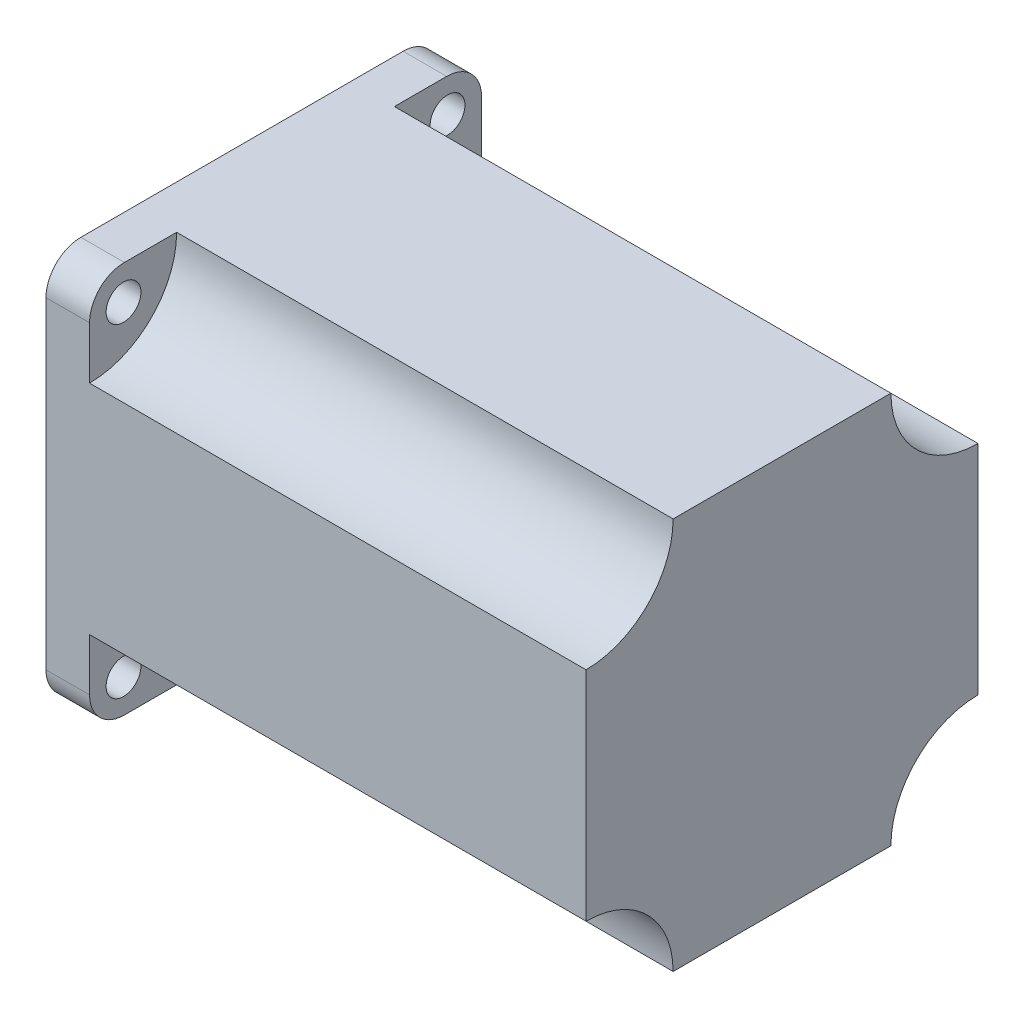
from build123d import *

# Parameters (mm, degrees)
SKETCH1_W           = 57.15
SKETCH1_H           = 57.15
SKETCH1_R           = 2.54
BOSS_EXTRUDE1_DEPTH = 6.35
FILLET1_R           = 5.08
SKETCH5_R           = 19.05
BOSS_EXTRUDE4_DEPTH = 1.524
SKETCH6_R           = 3.175
BOSS_EXTRUDE5_DEPTH = 19.05
BOSS_EXTRUDE6_DEPTH = 72.39


with BuildPart() as part:
    # Sketch1 → Boss-Extrude1 (new body)
    with BuildSketch(Plane(origin=(0, 0, 0), x_dir=(0, 0, -1), z_dir=(1, 0, 0))):
        Rectangle(SKETCH1_W, SKETCH1_H)
        with Locations((23.622, 23.622)):
            Circle(SKETCH1_R, mode=Mode.SUBTRACT)
        with Locations((-23.622, 23.622)):
            Circle(SKETCH1_R, mode=Mode.SUBTRACT)
        with Locations((-23.622, -23.622)):
            Circle(SKETCH1_R, mode=Mode.SUBTRACT)
        with Locations((23.622, -23.622)):
            Circle(SKETCH1_R, mode=Mode.SUBTRACT)
    extrude(amount=BOSS_EXTRUDE1_DEPTH)

    # Fillet1
    fillet1_edges = [part.edges().sort_by_distance(p)[0] for p in [
        (3.175, 28.575, 28.575),
        (3.175, 28.575, -28.575),
        (3.175, -28.575, -28.575),
        (3.175, -28.575, 28.575),
    ]]
    fillet(fillet1_edges, radius=FILLET1_R)

    # Sketch5 → Boss-Extrude4 (add)
    with BuildSketch(Plane.ZY):
        Circle(SKETCH5_R)
    extrude(amount=BOSS_EXTRUDE4_DEPTH)

    # Sketch6 → Boss-Extrude5 (add)
    with BuildSketch(Plane.ZY.offset(1.524)):
        Circle(SKETCH6_R)
    extrude(amount=BOSS_EXTRUDE5_DEPTH)

    # Sketch7 → Boss-Extrude6 (add)
    with BuildSketch(Plane(origin=(6.35, 0, 0), x_dir=(0, 0, -1), z_dir=(1, 0, 0))):
        with BuildLine():
            Line((-15.875, 28.575), (15.875, 28.575))
            ThreePointArc((15.875, 28.575), (19.594743879, 19.594743879), (28.575, 15.875))
            Line((28.575, 15.875), (28.575, -15.875))
            ThreePointArc((28.575, -15.875), (19.594743879, -19.594743879), (15.875, -28.575))
            Line((15.875, -28.575), (-15.875, -28.575))
            ThreePointArc((-15.875, -28.575), (-19.594743879, -19.594743879), (-28.575, -15.875))
            Line((-28.575, -15.875), (-28.575, 15.875))
            ThreePointArc((-28.575, 15.875), (-19.594743879, 19.594743879), (-15.875, 28.575))
        make_face()
    extrude(amount=BOSS_EXTRUDE6_DEPTH)


solid = part.part
